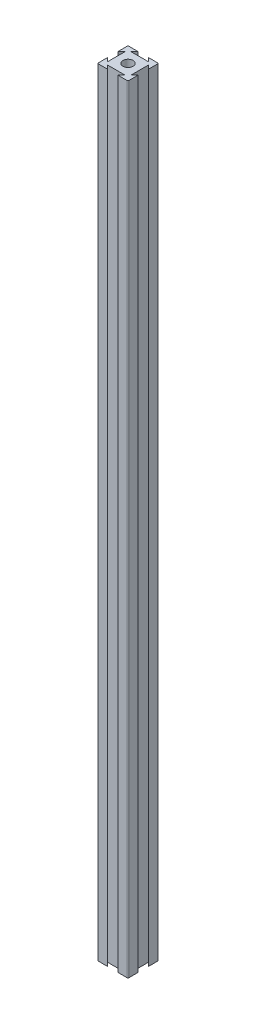
from build123d import *

# Parameters (mm, degrees)
SKETCH1_R           = 3.333333333
BOSS_EXTRUDE1_DEPTH = 508.762
FILLET4_R           = 0.508


with BuildPart() as part:
    # Sketch1 → Boss-Extrude1 (new body)
    with BuildSketch(Plane(origin=(0, 0, 0), x_dir=(1, 0, 0), z_dir=(0, 1, 0))):
        Polygon((4.285, 17.618333333), (6.666666667, 20), (0, 20), (0, 13.333333333), (2.381666667, 15.715), (2.381666667, 4.285), (0, 6.666666667), (0, 0), (6.666666667, 0), (4.285, 2.381666667), (15.715, 2.381666667), (13.333333333, 0), (20, 0), (20, 6.666666667), (17.618333333, 4.285), (17.618333333, 15.715), (20, 13.333333333), (20, 20), (13.333333333, 20), (15.715, 17.618333333), align=None)
        with Locations((10, 10)):
            Circle(SKETCH1_R, mode=Mode.SUBTRACT)
    extrude(amount=BOSS_EXTRUDE1_DEPTH)

    # Fillet4
    fillet4_edges = [part.edges().sort_by_distance(p)[0] for p in [
        (20, 254.381, 0),
        (0, 254.381, 0),
        (0, 254.381, -20),
        (20, 254.381, -20),
    ]]
    fillet(fillet4_edges, radius=FILLET4_R)


solid = part.part
